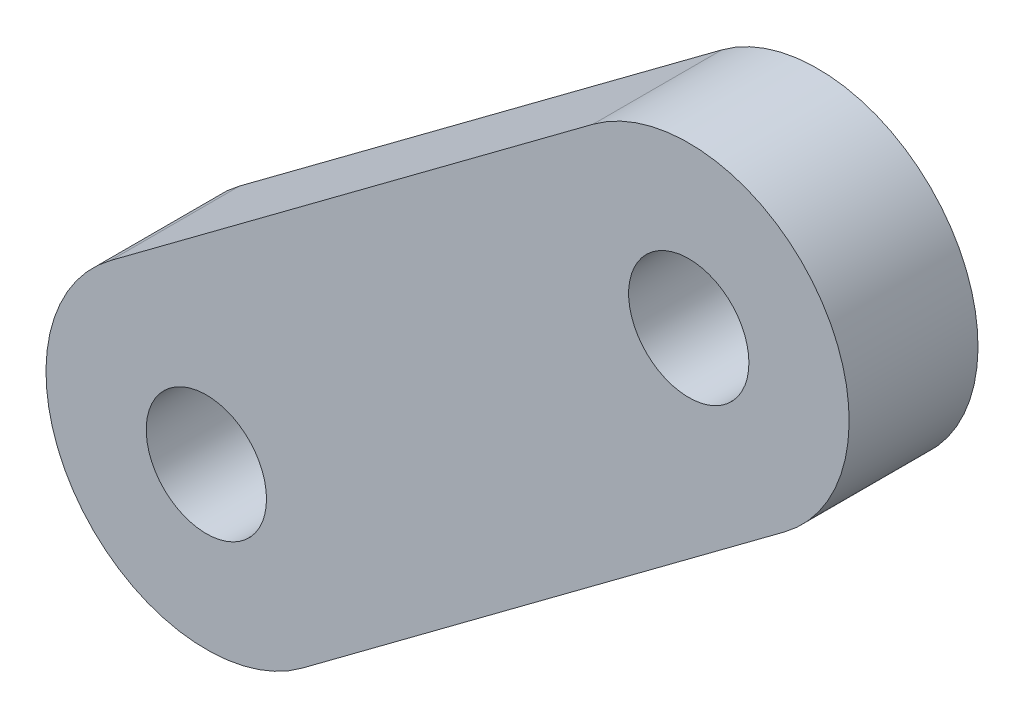
from build123d import *

# Parameters (mm, degrees)
SKETCH1_R           = 1.4
BOSS_EXTRUDE1_DEPTH = 3


with BuildPart() as part:
    # Sketch1 → Boss-Extrude1 (new body)
    with BuildSketch(Plane.XY):
        with BuildLine():
            Line((3.963608483, 7.081282642), (-7.265767332, -1.279406253))
            ThreePointArc((-7.265767332, -1.279406253), (-8.030750511, -6.503423509), (-2.806733255, -7.268406688))
            Line((-2.806733255, -7.268406688), (8.42264256, 1.092282207))
            ThreePointArc((8.42264256, 1.092282207), (9.187625739, 6.316299463), (3.963608483, 7.081282642))
        make_face()
        with Locations((6.193125522, 4.086782424)):
            Circle(SKETCH1_R, mode=Mode.SUBTRACT)
        with Locations((-5.036250293, -4.273906471)):
            Circle(SKETCH1_R, mode=Mode.SUBTRACT)
    extrude(amount=BOSS_EXTRUDE1_DEPTH)


solid = part.part
